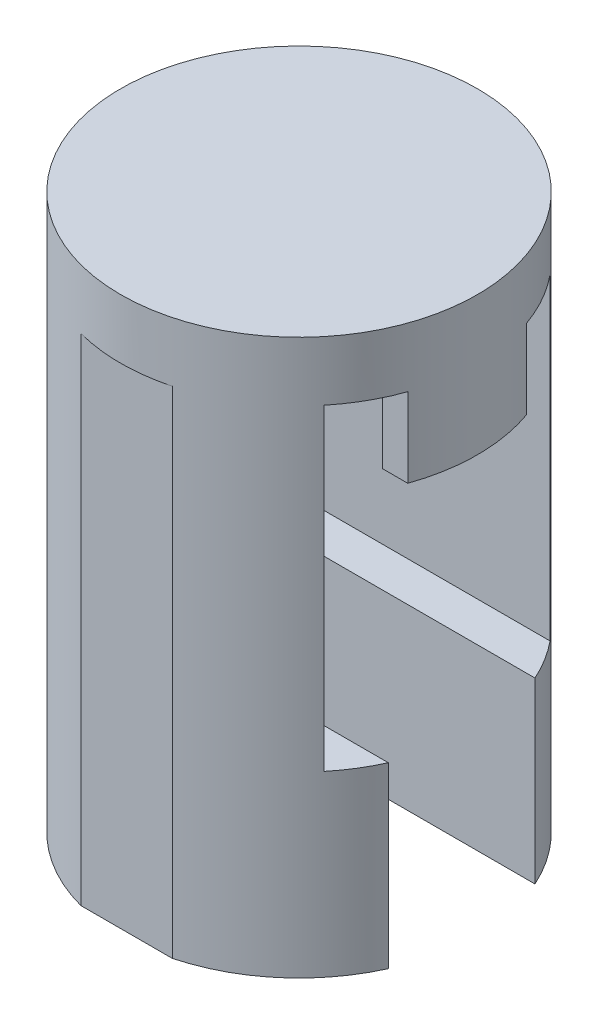
from build123d import *
from build123d.topology import SkipClean

# Parameters (mm, degrees)
SKETCH1_R           = 4.5
BOSS_EXTRUDE1_DEPTH = 1.5
BOSS_EXTRUDE2_START = 2
BOSS_EXTRUDE2_DEPTH = 2
BOSS_EXTRUDE3_START = 6
BOSS_EXTRUDE3_DEPTH = 6
BOSS_EXTRUDE4_START = 4.5
BOSS_EXTRUDE4_DEPTH = 4.5


with BuildPart() as part:
    # Sketch1 → Boss-Extrude1 (new body)
    with BuildSketch(Plane(origin=(0, 0, 0), x_dir=(1, 0, 0), z_dir=(0, 1, 0))):
        Circle(SKETCH1_R)
    extrude(amount=BOSS_EXTRUDE1_DEPTH)

    # Sketch2 → Boss-Extrude2 (add)
    with SkipClean():  # the faces are left unmerged after this step: merging them gives an invalid solid
        with BuildSketch(Plane.XZ.offset(BOSS_EXTRUDE2_START)):
            with BuildLine():
                ThreePointArc((-1.152171862, 4.35), (-2.43566088, 3.783854658), (-3.48245603, 2.85))
                Line((-3.48245603, 2.85), (3.48245603, 2.85))
                ThreePointArc((3.48245603, 2.85), (2.43566088, 3.783854658), (1.152171862, 4.35))
                Line((1.152171862, 4.35), (-1.152171862, 4.35))
            make_face()
            with BuildLine():
                Line((-3.6, 1.5), (-4.242640687, 1.5))
                ThreePointArc((-4.242640687, 1.5), (-4.5, 0), (-4.242640687, -1.5))
                Line((-4.242640687, -1.5), (-3.6, -1.5))
                ThreePointArc((-3.6, -1.5), (-3.9, 0), (-3.6, 1.5))
            make_face()
            with BuildLine():
                Line((4.242640687, 1.5), (3.6, 1.5))
                ThreePointArc((3.6, 1.5), (3.9, 0), (3.6, -1.5))
                Line((3.6, -1.5), (4.242640687, -1.5))
                ThreePointArc((4.242640687, -1.5), (4.5, 0), (4.242640687, 1.5))
            make_face()
            with BuildLine():
                Line((3.48245603, -2.85), (-3.48245603, -2.85))
                ThreePointArc((-3.48245603, -2.85), (-2.43566088, -3.783854658), (-1.152171862, -4.35))
                Line((-1.152171862, -4.35), (1.152171862, -4.35))
                ThreePointArc((1.152171862, -4.35), (2.43566088, -3.783854658), (3.48245603, -2.85))
            make_face()
        extrude(amount=-BOSS_EXTRUDE2_DEPTH)

    # Sketch3 → Boss-Extrude3 (add)
    with SkipClean():  # the faces are left unmerged after this step: merging them gives an invalid solid
        with BuildSketch(Plane.XZ.offset(2).offset(BOSS_EXTRUDE3_START)):
            with BuildLine():
                ThreePointArc((-1.152171862, 4.35), (-2.43566088, 3.783854658), (-3.48245603, 2.85))
                Line((-3.48245603, 2.85), (3.48245603, 2.85))
                ThreePointArc((3.48245603, 2.85), (2.43566088, 3.783854658), (1.152171862, 4.35))
                Line((1.152171862, 4.35), (-1.152171862, 4.35))
            make_face()
            with BuildLine():
                Line((3.48245603, -2.85), (-3.48245603, -2.85))
                ThreePointArc((-3.48245603, -2.85), (-2.43566088, -3.783854658), (-1.152171862, -4.35))
                Line((-1.152171862, -4.35), (1.152171862, -4.35))
                ThreePointArc((1.152171862, -4.35), (2.43566088, -3.783854658), (3.48245603, -2.85))
            make_face()
        extrude(amount=-BOSS_EXTRUDE3_DEPTH)

    # Sketch4 → Boss-Extrude4 (add)
    with SkipClean():  # the faces are left unmerged after this step: merging them gives an invalid solid
        with BuildSketch(Plane.XZ.offset(8).offset(BOSS_EXTRUDE4_START)):
            with BuildLine():
                Line((-1.152171862, -4.35), (1.152171862, -4.35))
                ThreePointArc((1.152171862, -4.35), (2.909369597, -3.433011586), (4.102133591, -1.85))
                Line((4.102133591, -1.85), (-4.102133591, -1.85))
                ThreePointArc((-4.102133591, -1.85), (-2.909369597, -3.433011586), (-1.152171862, -4.35))
            make_face()
            with BuildLine():
                ThreePointArc((-1.152171862, 4.35), (-2.909369597, 3.433011586), (-4.102133591, 1.85))
                Line((-4.102133591, 1.85), (4.102133591, 1.85))
                ThreePointArc((4.102133591, 1.85), (2.909369597, 3.433011586), (1.152171862, 4.35))
                Line((1.152171862, 4.35), (-1.152171862, 4.35))
            make_face()
        extrude(amount=-BOSS_EXTRUDE4_DEPTH)


solid = part.part
